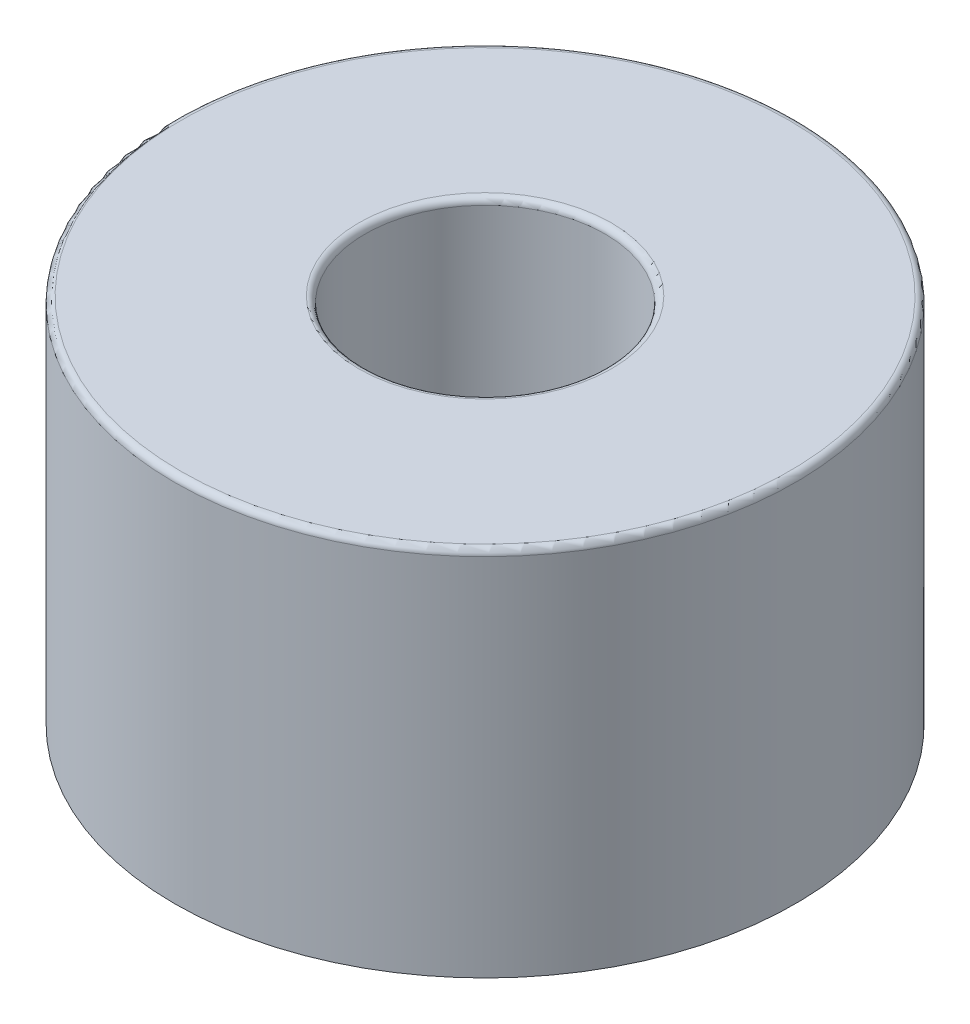
from build123d import *

# Parameters (mm, degrees)
SKETCH1_R           = 12.319
SKETCH1_R_2         = 4.7625
BOSS_EXTRUDE1_DEPTH = 14.732
FILLET1_R           = 0.254


with BuildPart() as part:
    # Sketch1 → Boss-Extrude1 (new body)
    with BuildSketch(Plane(origin=(0, 0, 0), x_dir=(1, 0, 0), z_dir=(0, 1, 0))):
        Circle(SKETCH1_R)
        Circle(SKETCH1_R_2, mode=Mode.SUBTRACT)
    extrude(amount=BOSS_EXTRUDE1_DEPTH)

    # Fillet1
    fillet1_edges = [part.edges().sort_by_distance(p)[0] for p in [
        (-12.319, 14.732, 0),
        (-4.7625, 14.732, 0),
    ]]
    fillet(fillet1_edges, radius=FILLET1_R)


solid = part.part
